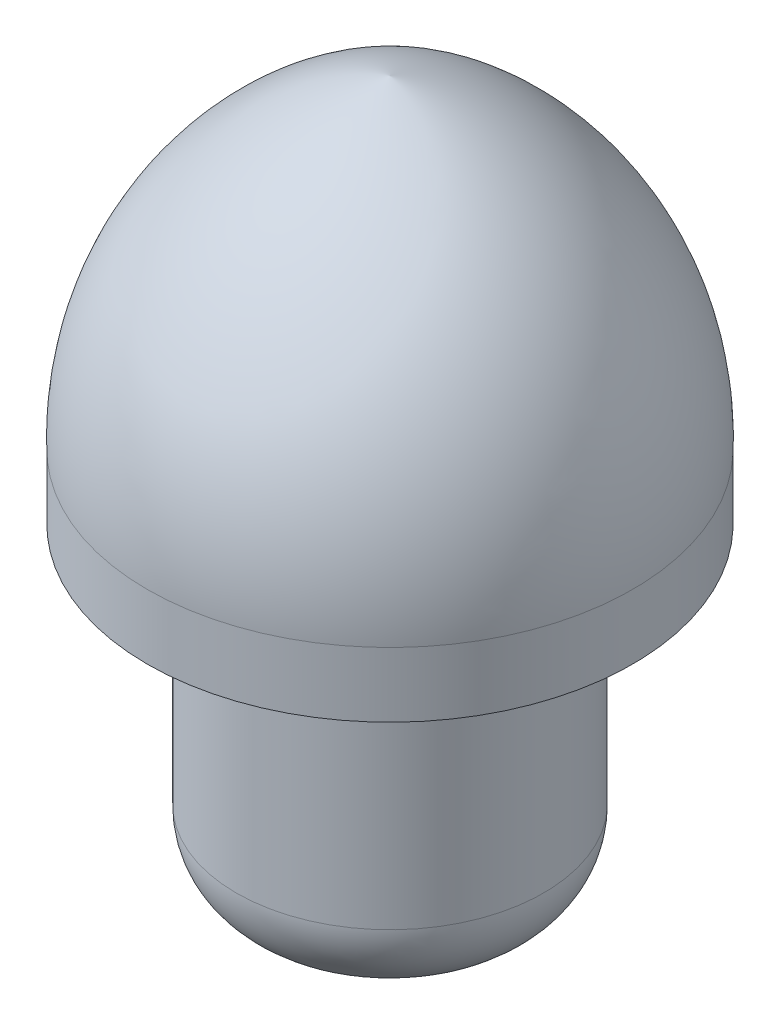
from build123d import *

# Parameters (mm, degrees)
ESBO_O4_R                     = 15
RESSALTO_EXTRUS_O1_DEPTH      = 1
RESSALTO_EXTRUS_O1_DEPTH_BACK = 4
ESBO_O5_R                     = 9.5
RESSALTO_EXTRUS_O2_DEPTH      = 20
FILETE1_R                     = 5


with BuildPart() as part:
    # Esboço3 → Revolução1 (revolve)
    with BuildSketch(Plane.XY):
        with BuildLine():
            ThreePointArc((-14, 0), (-10.249036326, 11.894026766), (0, 19))
            Line((0, 19), (0, 20))
            ThreePointArc((0, 20), (-11.010004003, 12.632503002), (-15, 0))
            Line((-15, 0), (-14, 0))
        make_face()
    revolve(axis=Axis((0, 0, 0), (0, 1, 0)))

    # Esboço4 → Ressalto-extrusão1 (add, two sides)
    with BuildSketch(Plane(origin=(0, 0, 0), x_dir=(1, 0, 0), z_dir=(0, 1, 0))) as ressalto_extrus_o1_sk:
        Circle(ESBO_O4_R)
    extrude(amount=RESSALTO_EXTRUS_O1_DEPTH)
    extrude(ressalto_extrus_o1_sk.sketch, amount=-RESSALTO_EXTRUS_O1_DEPTH_BACK)

    # Esboço5 → Ressalto-extrusão2 (add)
    with BuildSketch(Plane(origin=(0, -4, 0), x_dir=(-1, 0, 0), z_dir=(0, -1, 0))):
        Circle(ESBO_O5_R)
    extrude(amount=RESSALTO_EXTRUS_O2_DEPTH)

    # Filete1
    filete1_edges = [part.edges().sort_by_distance(p)[0] for p in [
        (9.5, -24, 0),
    ]]
    fillet(filete1_edges, radius=FILETE1_R)


solid = part.part
